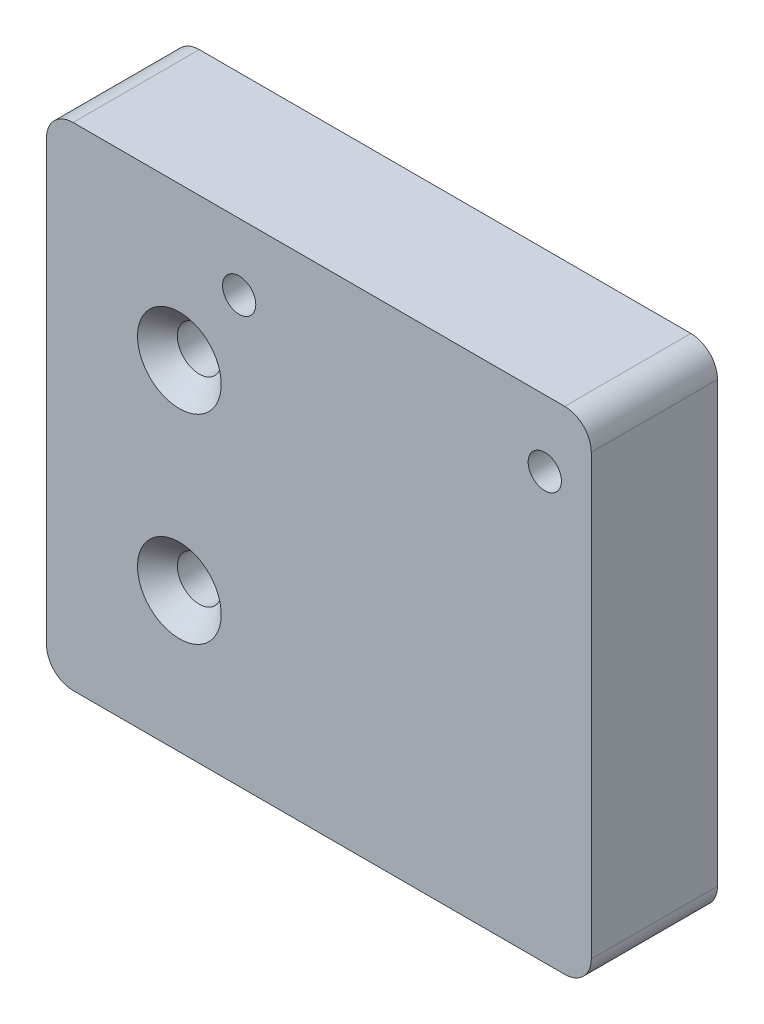
from build123d import *

# Parameters (mm, degrees)
SKETCH1_W                                           = 81.999999998
SKETCH1_H                                           = 60
BOSS_EXTRUDE1_DEPTH                                 = 19
TAP_DRILL_FOR_M6_TAP1_D                             = 5
CSK_FOR_M6_COUNTERSUNK_FLAT_HEAD_SCREW1_D           = 6.6
CSK_FOR_M6_COUNTERSUNK_FLAT_HEAD_SCREW1_CSINK_D     = 12.6
CSK_FOR_M6_COUNTERSUNK_FLAT_HEAD_SCREW1_CSINK_ANGLE = 90
SKETCH7_W                                           = 81.999999998
SKETCH7_H                                           = 14.054377775
BOSS_EXTRUDE2_DEPTH                                 = 19
TAP_DRILL_FOR_M5_TAP1_D                             = 4.2
TAP_DRILL_FOR_M5_TAP1_DEPTH                         = 30
TAP_DRILL_FOR_M5_TAP1_TIP                           = 1.2618073
FILLET1_R                                           = 4


with BuildPart() as part:
    # Sketch1 → Boss-Extrude1 (new body)
    with BuildSketch(Plane.XY):
        with Locations((20.999999999, 42.839007865)):
            Rectangle(SKETCH1_W, SKETCH1_H)
    extrude(amount=BOSS_EXTRUDE1_DEPTH)

    # Tap Drill for M6 Tap1 (through all)
    with Locations(Plane.XY.offset(19)):
        with Locations((8.999999998, 62.839007865), (54.999999998, 62.839007865)):
            Hole(TAP_DRILL_FOR_M6_TAP1_D / 2)

    # CSK for M6 Countersunk Flat Head Screw1 (through all)
    with Locations(Plane.XY.offset(19)):
        with Locations((0, 19.839007865), (0, 49.839007865)):
            CounterSinkHole(CSK_FOR_M6_COUNTERSUNK_FLAT_HEAD_SCREW1_D / 2, CSK_FOR_M6_COUNTERSUNK_FLAT_HEAD_SCREW1_CSINK_D / 2, counter_sink_angle=CSK_FOR_M6_COUNTERSUNK_FLAT_HEAD_SCREW1_CSINK_ANGLE)

    # Sketch7 → Boss-Extrude2 (add)
    with BuildSketch(Plane.XY.offset(19)):
        with Locations((20.999999999, 5.816196753)):
            Rectangle(SKETCH7_W, SKETCH7_H)
    extrude(amount=-BOSS_EXTRUDE2_DEPTH)

    # Tap Drill for M5 Tap1
    with Locations(Plane(origin=(0, -1.210992135, 0), x_dir=(-1, 0, 0), z_dir=(0, -1, 0))):
        with Locations((-41.999999998, -9.5)):
            Hole(TAP_DRILL_FOR_M5_TAP1_D / 2, depth=TAP_DRILL_FOR_M5_TAP1_DEPTH)
            with Locations((0, 0, -(TAP_DRILL_FOR_M5_TAP1_DEPTH + TAP_DRILL_FOR_M5_TAP1_TIP / 2))):  # 118° drill point
                Cone(0, TAP_DRILL_FOR_M5_TAP1_D / 2, TAP_DRILL_FOR_M5_TAP1_TIP, mode=Mode.SUBTRACT)

    # Fillet1
    fillet1_edges = [part.edges().sort_by_distance(p)[0] for p in [
        (-20, -1.210992135, 9.5),
        (61.999999998, -1.210992135, 9.5),
        (-20, 72.839007865, 9.5),
        (61.999999998, 72.839007865, 9.5),
    ]]
    fillet(fillet1_edges, radius=FILLET1_R)


solid = part.part
